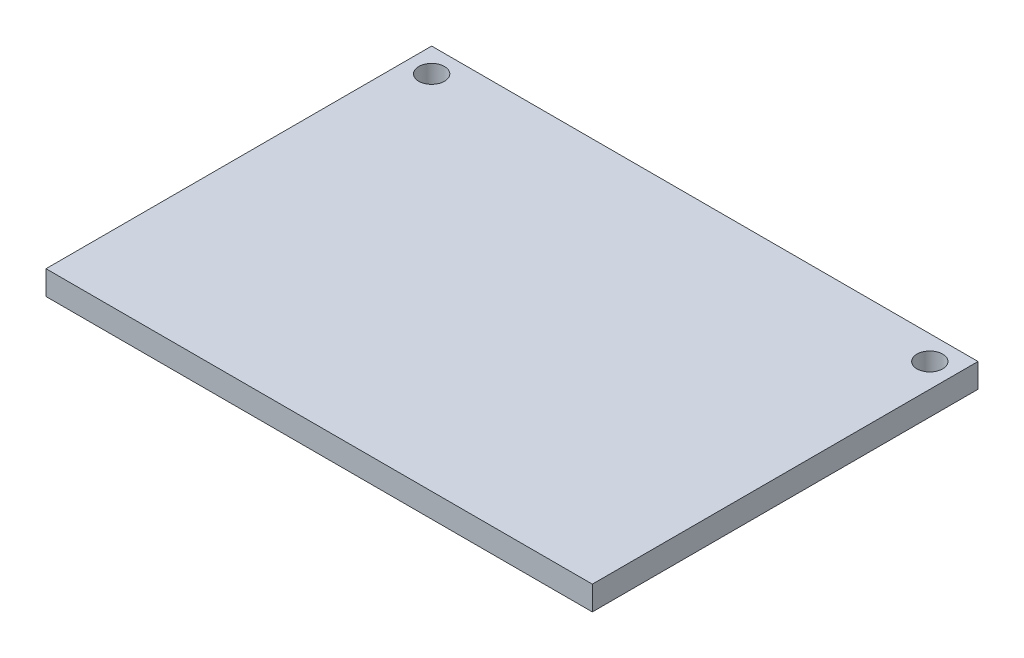
from build123d import *

# Parameters (mm, degrees)
SKETCH5_W           = 68
SKETCH5_H           = 48
SKETCH5_R           = 1.6
BOSS_EXTRUDE2_DEPTH = 3


with BuildPart() as part:
    # Sketch5 → Boss-Extrude2 (new body)
    with BuildSketch(Plane(origin=(0, 0, 0), x_dir=(1, 0, 0), z_dir=(0, 1, 0))):
        with Locations((-77.795731707, 1.464939024)):
            Rectangle(SKETCH5_W, SKETCH5_H)
        with Locations((-108.795731707, 22.464939024)):
            Circle(SKETCH5_R, mode=Mode.SUBTRACT)
        with Locations((-46.795731707, 22.464939024)):
            Circle(SKETCH5_R, mode=Mode.SUBTRACT)
    extrude(amount=BOSS_EXTRUDE2_DEPTH)


solid = part.part
